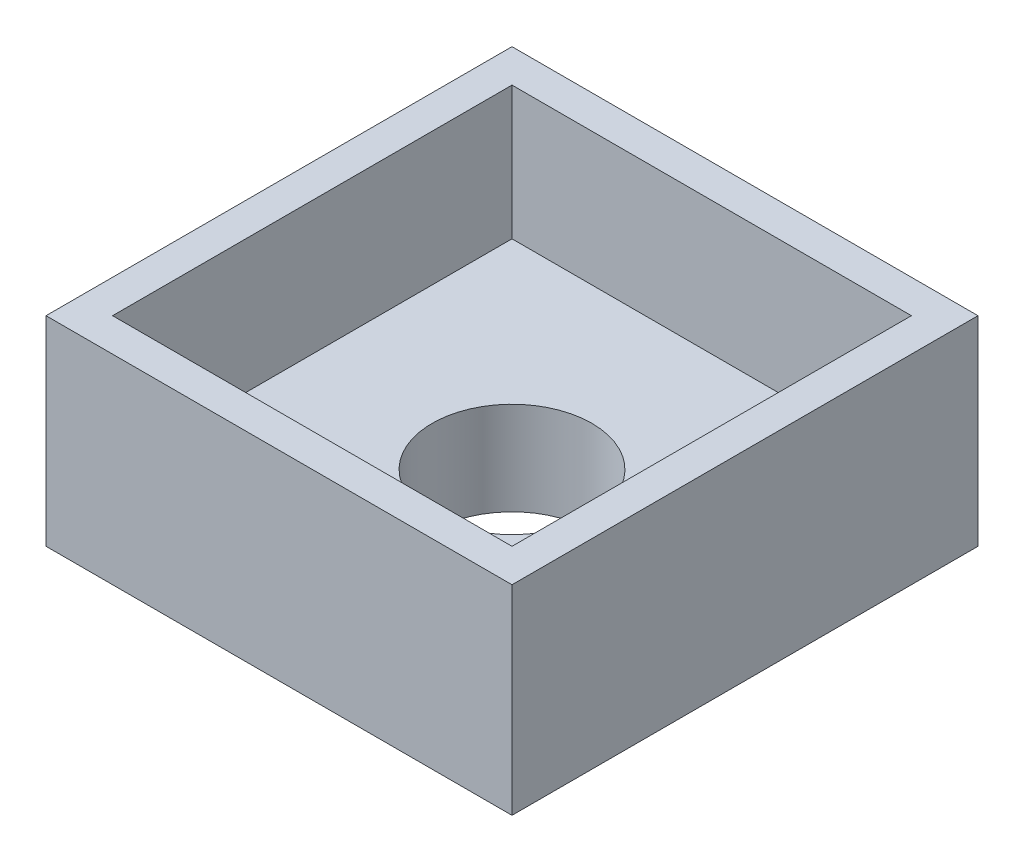
from build123d import *

# Parameters (mm, degrees)
SKETCH1_W           = 35
SKETCH1_H           = 35
SKETCH1_W_2         = 30
SKETCH1_H_2         = 30
BOSS_EXTRUDE1_DEPTH = 10
SKETCH4_W           = 35
SKETCH4_H           = 35
BOSS_EXTRUDE2_DEPTH = 5
SKETCH5_R           = 6
CUT_EXTRUDE1_DEPTH  = 29.939592257
SKETCH6_R           = 7
SKETCH6_R_2         = 6
BOSS_EXTRUDE3_DEPTH = 2


with BuildPart() as part:
    # Sketch1 → Boss-Extrude1 (new body)
    with BuildSketch(Plane(origin=(0, 0, 0), x_dir=(1, 0, 0), z_dir=(0, 1, 0))):
        Rectangle(SKETCH1_W, SKETCH1_H)
        Rectangle(SKETCH1_W_2, SKETCH1_H_2, mode=Mode.SUBTRACT)
    extrude(amount=BOSS_EXTRUDE1_DEPTH)

    # Sketch4 → Boss-Extrude2 (add)
    with BuildSketch(Plane.XZ):
        Rectangle(SKETCH4_W, SKETCH4_H)
    extrude(amount=BOSS_EXTRUDE2_DEPTH)

    # Sketch5 → Cut-Extrude1 (cut, through all)
    with BuildSketch(Plane.XZ.offset(5)):
        with Locations(Location((0, 0, 0), (0, 0, 270))):
            Circle(SKETCH5_R)
    extrude(amount=-CUT_EXTRUDE1_DEPTH, mode=Mode.SUBTRACT)

    # Sketch6 → Boss-Extrude3 (add)
    with BuildSketch(Plane(origin=(0, -5, 0), x_dir=(-1, 0, 0), z_dir=(0, -1, 0))):
        with Locations(Location((0, 0, 0), (0, 0, 270))):
            Circle(SKETCH6_R)
        with Locations(Location((0, 0, 0), (0, 0, 90))):
            Circle(SKETCH6_R_2, mode=Mode.SUBTRACT)
    extrude(amount=BOSS_EXTRUDE3_DEPTH)


solid = part.part
